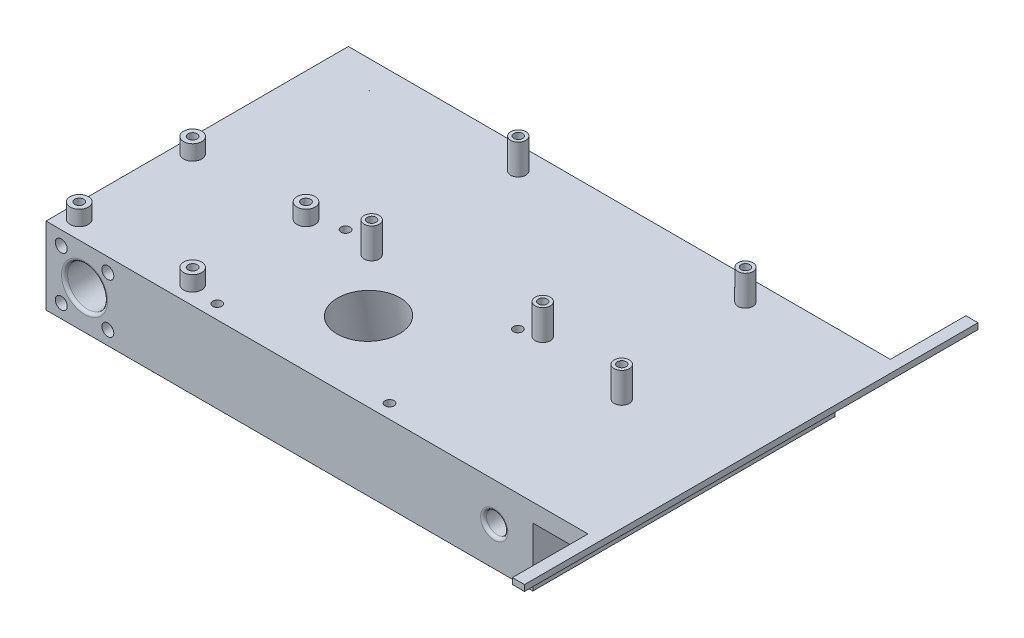
from build123d import *

# Parameters (mm, degrees)
SKETCH1_W                = 161
SKETCH1_H                = 100
BOSS_EXTRUDE1_DEPTH      = 12.75
BOSS_EXTRUDE1_DEPTH_BACK = 12.75
SKETCH2_R                = 6.63
SKETCH2_R_2              = 3.525
SKETCH2_R_3              = 1.975
CUT_EXTRUDE1_DEPTH       = 101
FILLET1_R                = 1
FILLET2_R                = 1
FILLET3_R                = 1
FILLET4_R                = 1
SKETCH3_R                = 2.5
BOSS_EXTRUDE2_DEPTH      = 10
SKETCH4_R                = 1.45
CUT_EXTRUDE2_DEPTH       = 5
SKETCH5_W                = 6
SKETCH5_H                = 13
CUT_EXTRUDE3_DEPTH       = 19.25
SKETCH6_R                = 10.25
CUT_EXTRUDE4_DEPTH       = 43.477415469
SKETCH8_R                = 1.5
CUT_EXTRUDE5_DEPTH       = 36.5
SKETCH11_R               = 3
BOSS_EXTRUDE4_DEPTH      = 5
SKETCH12_R               = 1.5
CUT_EXTRUDE7_DEPTH       = 5
SKETCH13_W               = 18.25
SKETCH13_H               = 6
BOSS_EXTRUDE5_DEPTH      = 100
SKETCH14_W               = 4
SKETCH14_H               = 2
BOSS_EXTRUDE6_DEPTH      = 25
BOSS_EXTRUDE6_DEPTH_BACK = 125


with BuildPart() as part:
    # Sketch1 → Boss-Extrude1 (new body, two sides)
    with BuildSketch(Plane(origin=(0, 0, 0), x_dir=(1, 0, 0), z_dir=(0, 1, 0))) as boss_extrude1_sk:
        Rectangle(SKETCH1_W, SKETCH1_H)
    extrude(amount=BOSS_EXTRUDE1_DEPTH)
    extrude(boss_extrude1_sk.sketch, amount=-BOSS_EXTRUDE1_DEPTH_BACK)

    # Sketch2 → Cut-Extrude1 (cut, through all)
    with BuildSketch(Plane.XY.offset(50)):
        with Locations((-67.75, 0)):
            Circle(SKETCH2_R)
        with Locations((67.75, 0)):
            Circle(SKETCH2_R_2)
        with Locations((-75.45, 8.2)):
            Circle(SKETCH2_R_3)
        with Locations((-75.45, -8.2)):
            Circle(SKETCH2_R_3)
        with Locations((-60.05, -8.2)):
            Circle(SKETCH2_R_3)
        with Locations((-60.05, 8.2)):
            Circle(SKETCH2_R_3)
    extrude(amount=-CUT_EXTRUDE1_DEPTH, mode=Mode.SUBTRACT)

    # Fillet1
    fillet1_edges = [part.edges().sort_by_distance(p)[0] for p in [
        (-74.38, 0, -50),
    ]]
    fillet(fillet1_edges, radius=FILLET1_R)

    # Fillet2
    fillet2_edges = [part.edges().sort_by_distance(p)[0] for p in [
        (-74.38, 0, 50),
    ]]
    fillet(fillet2_edges, radius=FILLET2_R)

    # Fillet3
    fillet3_edges = [part.edges().sort_by_distance(p)[0] for p in [
        (64.225, 0, 50),
    ]]
    fillet(fillet3_edges, radius=FILLET3_R)

    # Fillet4
    fillet4_edges = [part.edges().sort_by_distance(p)[0] for p in [
        (64.225, 0, -50),
    ]]
    fillet(fillet4_edges, radius=FILLET4_R)

    # Sketch3 → Boss-Extrude2 (add)
    with BuildSketch(Plane(origin=(0, 12.75, 0), x_dir=(1, 0, 0), z_dir=(0, 1, 0))):
        with Locations((-16.76, 42.46)):
            Circle(SKETCH3_R)
        with Locations((58.37, 42.46)):
            Circle(SKETCH3_R)
        with Locations((-17, -5.8)):
            Circle(SKETCH3_R)
        with Locations((34.7, -0.9)):
            Circle(SKETCH3_R)
        with Locations((65.72, -5.8)):
            Circle(SKETCH3_R)
    extrude(amount=BOSS_EXTRUDE2_DEPTH)

    # Sketch4 → Cut-Extrude2 (cut)
    with BuildSketch(Plane(origin=(0, 22.75, 0), x_dir=(1, 0, 0), z_dir=(0, 1, 0))):
        with Locations((-16.76, 42.46)):
            Circle(SKETCH4_R)
        with Locations((-17, -5.8)):
            Circle(SKETCH4_R)
        with Locations((34.7, -0.9)):
            Circle(SKETCH4_R)
        with Locations((65.72, -5.8)):
            Circle(SKETCH4_R)
        with Locations((58.37, 42.46)):
            Circle(SKETCH4_R)
    extrude(amount=-CUT_EXTRUDE2_DEPTH, mode=Mode.SUBTRACT)

    # Sketch5 → Cut-Extrude3 (cut)
    with BuildSketch(Plane(origin=(80.5, 0, 0), x_dir=(0, 0, -1), z_dir=(1, 0, 0))):
        with Locations((-30, 0)):
            Rectangle(SKETCH5_W, SKETCH5_H)
        with Locations((-10, 0)):
            Rectangle(SKETCH5_W, SKETCH5_H)
        with Locations((10, 0)):
            Rectangle(SKETCH5_W, SKETCH5_H)
        with Locations((30, 0)):
            Rectangle(SKETCH5_W, SKETCH5_H)
    extrude(amount=-CUT_EXTRUDE3_DEPTH, mode=Mode.SUBTRACT)

    # Sketch6 → Cut-Extrude4 (cut, through all)
    with BuildSketch(Plane(origin=(0, 20.916044041, 3.688062894), x_dir=(1, 0, 0), z_dir=(0, 0.984807753, 0.173648178))):
        with Locations((0, -21.249093385)):
            Circle(SKETCH6_R)
    extrude(amount=-CUT_EXTRUDE4_DEPTH, mode=Mode.SUBTRACT)

    # Sketch8 → Cut-Extrude5 (cut, through all)
    with BuildSketch(Plane.XZ.offset(12.75)):
        with Locations((28.5, 2.93086019)):
            Circle(SKETCH8_R)
        with Locations((28.5, 45.38111272)):
            Circle(SKETCH8_R)
        with Locations((-28.5, 2.93086019)):
            Circle(SKETCH8_R)
        with Locations((-28.5, 45.38111272)):
            Circle(SKETCH8_R)
    extrude(amount=-CUT_EXTRUDE5_DEPTH, mode=Mode.SUBTRACT)

    # Sketch11 → Boss-Extrude4 (add)
    with BuildSketch(Plane(origin=(0, 12.75, 0), x_dir=(1, 0, 0), z_dir=(0, 1, 0))):
        with Locations((-38, -6.5)):
            Circle(SKETCH11_R)
        with Locations((-38, -44)):
            Circle(SKETCH11_R)
        with Locations((-75.5, -6.5)):
            Circle(SKETCH11_R)
        with Locations((-75.5, -44)):
            Circle(SKETCH11_R)
    extrude(amount=BOSS_EXTRUDE4_DEPTH)

    # Sketch12 → Cut-Extrude7 (cut)
    with BuildSketch(Plane(origin=(0, 17.75, 0), x_dir=(1, 0, 0), z_dir=(0, 1, 0))):
        with Locations((-75.5, -44)):
            Circle(SKETCH12_R)
        with Locations((-75.5, -6.5)):
            Circle(SKETCH12_R)
        with Locations((-38, -6.5)):
            Circle(SKETCH12_R)
        with Locations((-38, -44)):
            Circle(SKETCH12_R)
    extrude(amount=-CUT_EXTRUDE7_DEPTH, mode=Mode.SUBTRACT)

    # Sketch13 → Boss-Extrude5 (add)
    with BuildSketch(Plane.XY.offset(50)):
        with Locations((89.625, 9.75)):
            Rectangle(SKETCH13_W, SKETCH13_H)
    extrude(amount=-BOSS_EXTRUDE5_DEPTH)

    # Sketch14 → Boss-Extrude6 (add, two sides)
    with BuildSketch(Plane.XY.offset(50)) as boss_extrude6_sk:
        with Locations((100.75, 11.75)):
            Rectangle(SKETCH14_W, SKETCH14_H)
    extrude(amount=BOSS_EXTRUDE6_DEPTH)
    extrude(boss_extrude6_sk.sketch, amount=-BOSS_EXTRUDE6_DEPTH_BACK)


solid = part.part
